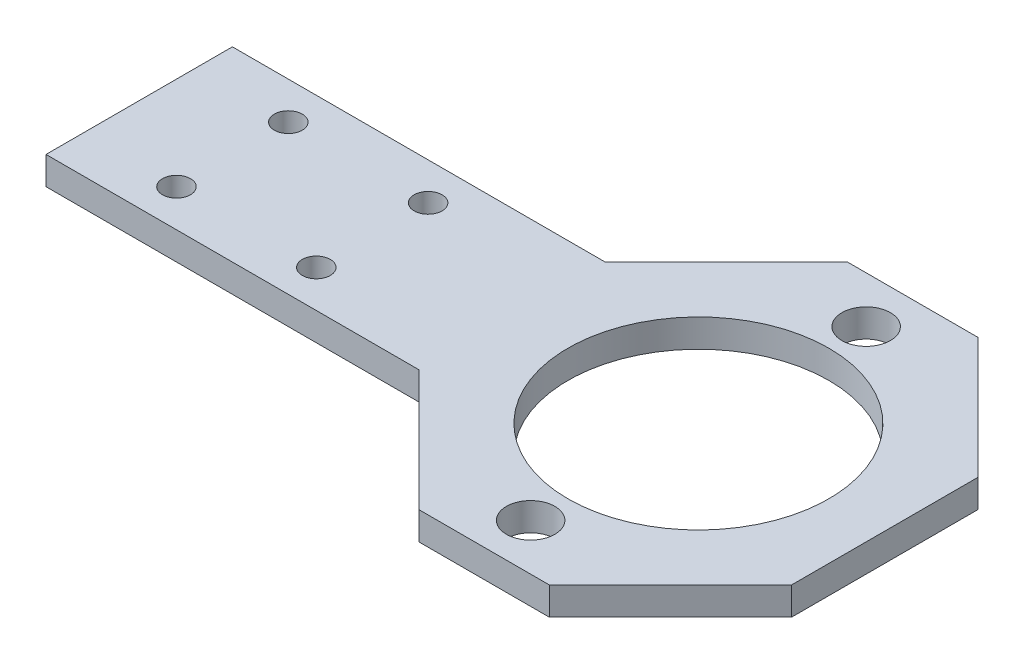
from build123d import *

# Parameters (mm, degrees)
SKETCH_1_R      = 1.5
SKETCH_1_R_2    = 14
SKETCH_1_R_3    = 2.6
EXTRUDE_1_DEPTH = 3


with BuildPart() as part:
    # 草图1 → 凸台-拉伸1 (new body)
    with BuildSketch(Plane(origin=(0, 0, 0), x_dir=(1, 0, 0), z_dir=(0, 1, 0))):
        Polygon((-60, 10), (-20, 10), (-7, 23), (7, 23), (20, 10), (20, -10), (7, -23), (-7, -23), (-20, -10), (-60, -10), align=None)
        with Locations((-35, 6)):
            Circle(SKETCH_1_R, mode=Mode.SUBTRACT)
        with Locations((-50, 6)):
            Circle(SKETCH_1_R, mode=Mode.SUBTRACT)
        with Locations((-35, -6)):
            Circle(SKETCH_1_R, mode=Mode.SUBTRACT)
        with Locations((-50, -6)):
            Circle(SKETCH_1_R, mode=Mode.SUBTRACT)
        Circle(SKETCH_1_R_2, mode=Mode.SUBTRACT)
        with Locations((0, 18)):
            Circle(SKETCH_1_R_3, mode=Mode.SUBTRACT)
        with Locations((0, -18)):
            Circle(SKETCH_1_R_3, mode=Mode.SUBTRACT)
    extrude(amount=EXTRUDE_1_DEPTH)


solid = part.part
